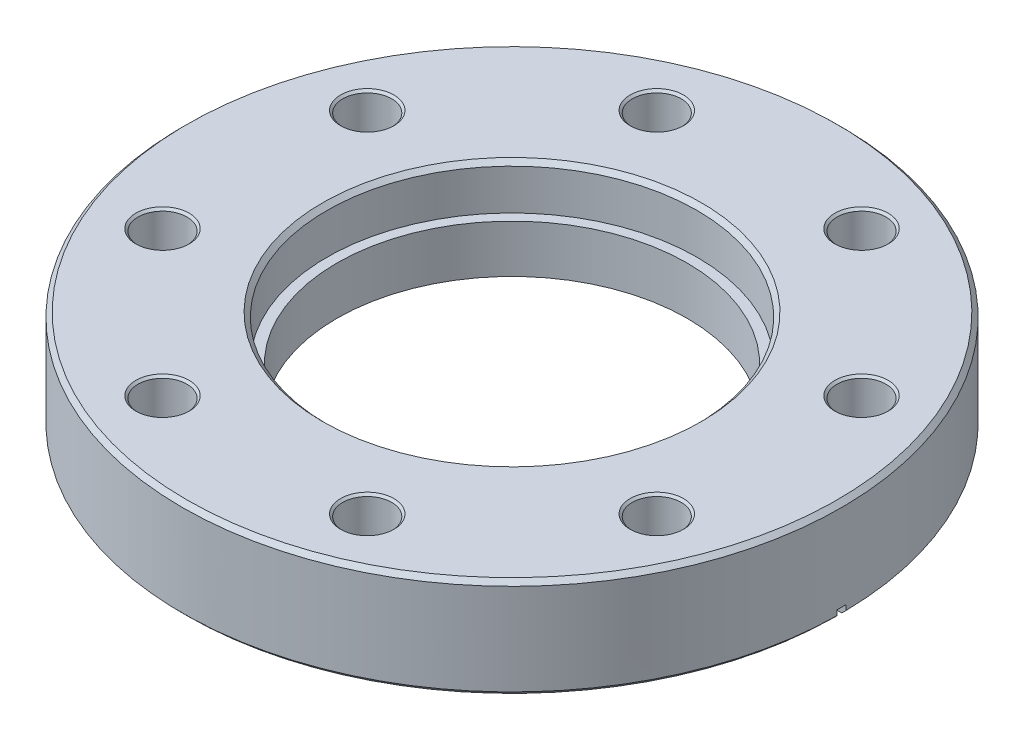
from build123d import *

# Parameters (mm, degrees)
SKETCH1_R                    = 56.769
SKETCH1_R_2                  = 30.1625
BOSS_EXTRUDE1_DEPTH          = 17.272
SKETCH2_R                    = 31.877
CUT_EXTRUDE1_DEPTH           = 7.747
CHAMFER1_SIZE                = 0.762
SKETCH4_R                    = 4.2164
CUT_EXTRUDE2_DEPTH           = 18.272
CHAMFER2_SIZE                = 0.381
CIRPATTERN1_COUNT            = 8
CHAMFER2_OF_CIRPATTERN1_SIZE = 0.381
CUT_EXTRUDE3_DEPTH           = 0.79375


with BuildPart() as part:
    # Sketch1 → Boss-Extrude1 (new body)
    with BuildSketch(Plane(origin=(0, 0, 0), x_dir=(1, 0, 0), z_dir=(0, 1, 0))):
        Circle(SKETCH1_R)
        Circle(SKETCH1_R_2, mode=Mode.SUBTRACT)
    extrude(amount=BOSS_EXTRUDE1_DEPTH)

    # Sketch2 → Cut-Extrude1 (cut)
    with BuildSketch(Plane(origin=(0, 17.272, 0), x_dir=(1, 0, 0), z_dir=(0, 1, 0))):
        Circle(SKETCH2_R)
    extrude(amount=-CUT_EXTRUDE1_DEPTH, mode=Mode.SUBTRACT)

    # Chamfer1
    chamfer1_edges = [part.edges().sort_by_distance(p)[0] for p in [
        (-31.877, 17.272, 0),
        (-56.769, 0, 0),
        (-56.769, 17.272, 0),
    ]]
    chamfer(chamfer1_edges, length=CHAMFER1_SIZE)

    # Sketch5 → Cut-Revolve1 (revolve, cut)
    with BuildSketch(Plane.XY):
        Polygon((-41.275, 0), (-41.275, 1.6256), (-38.608, 0.6604), (-38.608, 1.27), (0, 1.27), (0, 0), align=None)
    revolve(axis=Axis((0, 17.272, 0), (0, -1, 0)), mode=Mode.SUBTRACT)

    # Sketch4 → Cut-Extrude2 (cut, through all)
    with BuildSketch(Plane(origin=(0, 17.272, 0), x_dir=(1, 0, 0), z_dir=(0, 1, 0))):
        with Locations((-17.632368756, 42.568303788)):
            Circle(SKETCH4_R)
    cut_extrude2 = extrude(amount=-CUT_EXTRUDE2_DEPTH, mode=Mode.SUBTRACT)

    # Chamfer2
    chamfer2_edges = [part.edges().sort_by_distance(p)[0] for p in [
        (-21.848768756, 0, -42.568303788),
        (-21.848768756, 17.272, -42.568303788),
    ]]
    chamfer(chamfer2_edges, length=CHAMFER2_SIZE)

    # CirPattern1: Cut-Extrude2 ×8 about axis
    cirpattern1_axis = Axis((0, 0, 0), (0, 1, 0))
    for i in range(1, CIRPATTERN1_COUNT):
        add(cut_extrude2.rotate(cirpattern1_axis, i * 360 / CIRPATTERN1_COUNT), mode=Mode.SUBTRACT)

    # Chamfer2 of CirPattern1
    chamfer2_of_cirpattern1_edges = [part.edges().sort_by_distance(p)[0] for p in [
        (-45.54974882, 0, -14.650923724),
        (-45.54974882, 17.272, -14.650923724),
        (-42.568303788, 0, 21.848768756),
        (-42.568303788, 17.272, 21.848768756),
        (-14.650923724, 0, 45.54974882),
        (-14.650923724, 17.272, 45.54974882),
        (21.848768756, 0, 42.568303788),
        (21.848768756, 17.272, 42.568303788),
        (45.54974882, 0, 14.650923724),
        (45.54974882, 17.272, 14.650923724),
        (42.568303788, 0, -21.848768756),
        (42.568303788, 17.272, -21.848768756),
        (14.650923724, 0, -45.54974882),
        (14.650923724, 17.272, -45.54974882),
    ]]
    chamfer(chamfer2_of_cirpattern1_edges, length=CHAMFER2_OF_CIRPATTERN1_SIZE)

    # Sketch6 → Cut-Extrude3 (cut, symmetric)
    with BuildSketch(Plane.XY):
        Polygon((-40.64, 0.933144104), (-56.769, 1.778429176), (-56.769, -1.196708046), (-40.64, -1.196708046), align=None)
        Polygon((56.769, 1.645313417), (56.769, -1.196708046), (40.64, -1.196708046), (40.64, 0.800028345), align=None)
    extrude(amount=CUT_EXTRUDE3_DEPTH, both=True, mode=Mode.SUBTRACT)


solid = part.part
